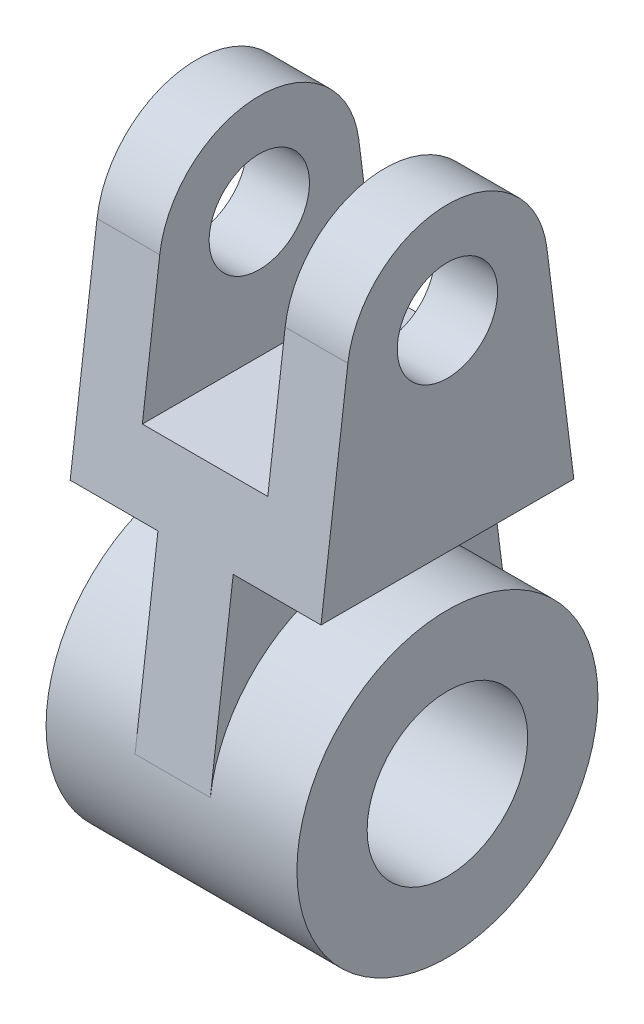
from build123d import *

# Parameters (mm, degrees)
SKETCH1_R               = 30
BOSS_EXTRUDE1_DEPTH     = 25
SKETCH2_R               = 16
CUT_EXTRUDE1_DEPTH      = 25
BOSS_EXTRUDE3_DEPTH     = 25
BOSS_EXTRUDE4_DEPTH     = 7.5
SKETCH4_R               = 10
CUT_EXTRUDE2_DEPTH      = 116.758369028
CUT_EXTRUDE3_DEPTH      = 108.354552768
CUT_EXTRUDE3_DEPTH_BACK = 108.354552768
SKETCH5_W               = 25
SKETCH5_H               = 45


with BuildPart() as part:
    # Sketch1 → Boss-Extrude1 (new, symmetric)
    with BuildSketch(Plane(origin=(0, 0, 0), x_dir=(0, 0, -1), z_dir=(1, 0, 0))):
        Circle(SKETCH1_R)
    extrude(amount=BOSS_EXTRUDE1_DEPTH, both=True)

    # Sketch2 → Cut-Extrude1 (cut, symmetric)
    with BuildSketch(Plane(origin=(0, 0, 0), x_dir=(0, 0, -1), z_dir=(1, 0, 0))):
        Circle(SKETCH2_R)
    extrude(amount=CUT_EXTRUDE1_DEPTH, both=True, mode=Mode.SUBTRACT)



with BuildPart() as body_2:
    # Sketch3 → Boss-Extrude3 (new, symmetric)
    with BuildSketch(Plane(origin=(0, 0, 0), x_dir=(0, 0, -1), z_dir=(1, 0, 0))):
        with BuildLine():
            Line((-19.843134833, 82.5), (-25.197631534, 40))
            Line((-25.197631534, 40), (25.197631534, 40))
            Line((25.197631534, 40), (19.843134833, 82.5))
            ThreePointArc((19.843134833, 82.5), (0, 100), (-19.843134833, 82.5))
        make_face()
    extrude(amount=BOSS_EXTRUDE3_DEPTH, both=True)


with BuildPart() as part_1:
    add(part.part)

    add(body_2.part)  # Boss-Extrude4 merges body 2
    # Sketch3_3 → Boss-Extrude4 (add, symmetric)
    with BuildSketch(Plane(origin=(0, 0, 0), x_dir=(0, 0, -1), z_dir=(1, 0, 0))):
        with BuildLine():
            ThreePointArc((-29.764702249, 3.75), (0, 30), (29.764702249, 3.75))
            Line((29.764702249, 3.75), (25.197631534, 40))
            Line((25.197631534, 40), (-25.197631534, 40))
            Line((-25.197631534, 40), (-29.764702249, 3.75))
        make_face()
    extrude(amount=BOSS_EXTRUDE4_DEPTH, both=True)

    # Sketch4 → Cut-Extrude2 (cut, through all)
    with BuildSketch(Plane(origin=(25, 0, 0), x_dir=(0, 0, -1), z_dir=(1, 0, 0))):
        with Locations((0, 80)):
            Circle(SKETCH4_R)
    extrude(amount=-CUT_EXTRUDE2_DEPTH, mode=Mode.SUBTRACT)

    # Sketch5 → Cut-Extrude3 (cut, two sides: drawn at the far end of the back side and taken through both)
    with BuildSketch(Plane.XY.offset(-CUT_EXTRUDE3_DEPTH_BACK)):
        with Locations((0, 77.5)):
            Rectangle(SKETCH5_W, SKETCH5_H)
    extrude(amount=CUT_EXTRUDE3_DEPTH + CUT_EXTRUDE3_DEPTH_BACK, mode=Mode.SUBTRACT)


solid = part_1.part
